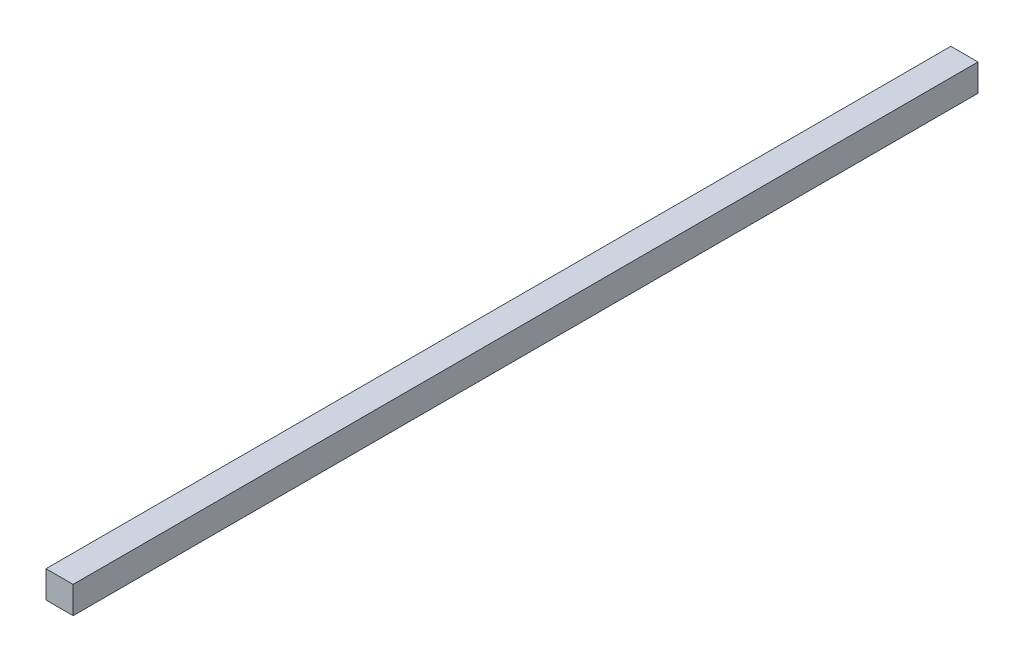
from build123d import *

# Parameters (mm, degrees)
SKETCH_1_W      = 3
SKETCH_1_H      = 3
EXTRUDE_1_DEPTH = 100


with BuildPart() as part:
    # 草图1 → 凸台-拉伸1 (new body)
    with BuildSketch(Plane.XY):
        with Locations((1.5, 1.5)):
            Rectangle(SKETCH_1_W, SKETCH_1_H)
    extrude(amount=EXTRUDE_1_DEPTH)


solid = part.part
